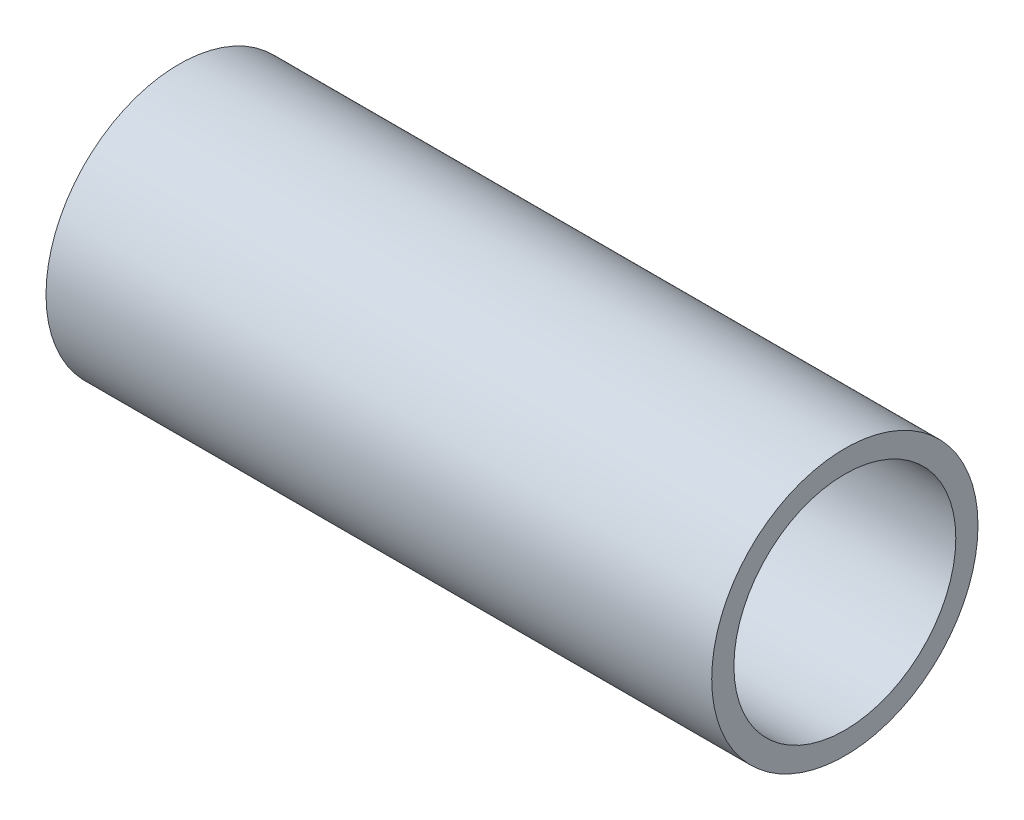
from build123d import *


with BuildPart() as part:
    # Sketch1 → Revolve1 (revolve)
    with BuildSketch(Plane(origin=(0, 0, 0), x_dir=(1, 0, 0), z_dir=(0, 1, 0))):
        Polygon((-8.721123036, 0), (-8.721123036, 3), (6.278876964, 3), (6.278876964, 2.5), (1.278876964, 2.5), (1.278876964, 0), align=None)
    revolve(axis=Axis((-26.913580247, 0, 0), (1, 0, 0)))


solid = part.part
